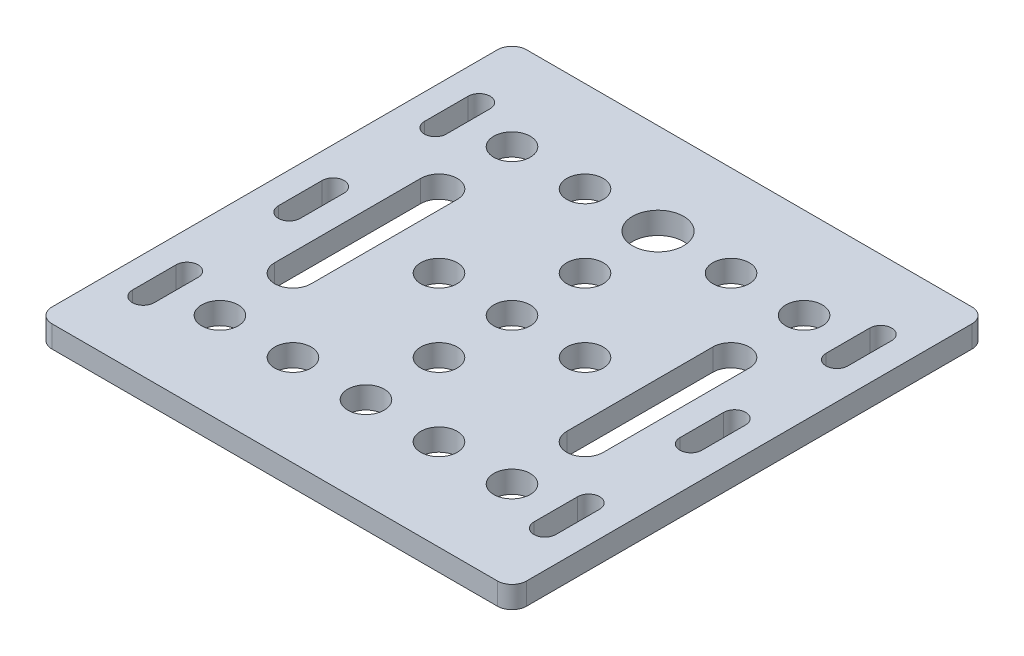
from build123d import *

# Parameters (mm, degrees)
SKETCH1_W               = 65
SKETCH1_H               = 65
BOSS_EXTRUDE1_DEPTH     = 1.5
CUT_EXTRUDE1_DEPTH      = 46.986411036
CUT_EXTRUDE1_DEPTH_BACK = 46.986411036
SKETCH2_R               = 2.5
CUT_EXTRUDE2_DEPTH      = 46.986411036
CUT_EXTRUDE2_DEPTH_BACK = 46.986411036
CUT_EXTRUDE3_DEPTH      = 46.986411036
CUT_EXTRUDE3_DEPTH_BACK = 46.986411036
SKETCH4_R               = 3.5
CUT_EXTRUDE4_DEPTH      = 46.986411036
CUT_EXTRUDE4_DEPTH_BACK = 46.986411036
FILLET1_R               = 2


with BuildPart() as part:
    # Sketch1 → Boss-Extrude1 (new, symmetric)
    with BuildSketch(Plane(origin=(0, 0, 0), x_dir=(1, 0, 0), z_dir=(0, 1, 0))):
        Rectangle(SKETCH1_W, SKETCH1_H)
    extrude(amount=BOSS_EXTRUDE1_DEPTH, both=True)

    # Sketch2 → Cut-Extrude1 (cut, two sides: drawn at the far end of the back side and taken through both)
    with BuildSketch(Plane(origin=(0, 0, 0), x_dir=(1, 0, 0), z_dir=(0, 1, 0)).offset(-CUT_EXTRUDE1_DEPTH_BACK)):
        Circle(SKETCH2_R)
        with Locations((0, 10)):
            Circle(SKETCH2_R)
        with Locations((0, -10)):
            Circle(SKETCH2_R)
        with Locations((0, -20)):
            Circle(SKETCH2_R)
        with Locations((-10, 0)):
            Circle(SKETCH2_R)
        with Locations((-10, 20)):
            Circle(SKETCH2_R)
        with Locations((-10, -20)):
            Circle(SKETCH2_R)
        with Locations((-20, 20)):
            Circle(SKETCH2_R)
        with Locations((-20, -20)):
            Circle(SKETCH2_R)
        with Locations((10, 0)):
            Circle(SKETCH2_R)
        with Locations((10, 20)):
            Circle(SKETCH2_R)
        with Locations((10, -20)):
            Circle(SKETCH2_R)
        with Locations((20, 20)):
            Circle(SKETCH2_R)
        with Locations((20, -20)):
            Circle(SKETCH2_R)
    extrude(amount=CUT_EXTRUDE1_DEPTH + CUT_EXTRUDE1_DEPTH_BACK, mode=Mode.SUBTRACT)

    # Sketch3 → Cut-Extrude2 (cut, two sides: drawn at the far end of the back side and taken through both)
    with BuildSketch(Plane(origin=(0, 0, 0), x_dir=(1, 0, 0), z_dir=(0, 1, 0)).offset(-CUT_EXTRUDE2_DEPTH_BACK)):
        with BuildLine():
            Line((22.5, 10), (22.5, -10))
            ThreePointArc((22.5, -10), (20, -12.5), (17.5, -10))
            Line((17.5, -10), (17.5, 10))
            ThreePointArc((17.5, 10), (20, 12.5), (22.5, 10))
        make_face()
        with BuildLine():
            Line((-22.5, 10), (-22.5, -10))
            ThreePointArc((-22.5, -10), (-20, -12.5), (-17.5, -10))
            Line((-17.5, -10), (-17.5, 10))
            ThreePointArc((-17.5, 10), (-20, 12.5), (-22.5, 10))
        make_face()
    extrude(amount=CUT_EXTRUDE2_DEPTH + CUT_EXTRUDE2_DEPTH_BACK, mode=Mode.SUBTRACT)

    # Sketch4 → Cut-Extrude3 (cut, two sides: drawn at the far end of the back side and taken through both)
    with BuildSketch(Plane(origin=(0, 0, 0), x_dir=(1, 0, 0), z_dir=(0, 1, 0)).offset(-CUT_EXTRUDE3_DEPTH_BACK)):
        with Locations((0, 20)):
            Circle(SKETCH4_R)
    extrude(amount=CUT_EXTRUDE3_DEPTH + CUT_EXTRUDE3_DEPTH_BACK, mode=Mode.SUBTRACT)

    # Sketch5 → Cut-Extrude4 (cut, two sides: drawn at the far end of the back side and taken through both)
    with BuildSketch(Plane(origin=(0, 0, 0), x_dir=(1, 0, 0), z_dir=(0, 1, 0)).offset(-CUT_EXTRUDE4_DEPTH_BACK)):
        with BuildLine():
            Line((29, -3), (29, 3))
            ThreePointArc((29, 3), (27.5, 4.5), (26, 3))
            Line((26, 3), (26, -3))
            ThreePointArc((26, -3), (27.5, -4.5), (29, -3))
        make_face()
        with BuildLine():
            Line((29, 17), (29, 23))
            ThreePointArc((29, 23), (27.5, 24.5), (26, 23))
            Line((26, 23), (26, 17))
            ThreePointArc((26, 17), (27.5, 15.5), (29, 17))
        make_face()
        with BuildLine():
            Line((29, -23), (29, -17))
            ThreePointArc((29, -17), (27.5, -15.5), (26, -17))
            Line((26, -17), (26, -23))
            ThreePointArc((26, -23), (27.5, -24.5), (29, -23))
        make_face()
        with BuildLine():
            ThreePointArc((-26, -17), (-27.5, -15.5), (-29, -17))
            Line((-29, -17), (-29, -23))
            ThreePointArc((-29, -23), (-27.5, -24.5), (-26, -23))
            Line((-26, -23), (-26, -17))
        make_face()
        with BuildLine():
            ThreePointArc((-26, 23), (-27.5, 24.5), (-29, 23))
            Line((-29, 23), (-29, 17))
            ThreePointArc((-29, 17), (-27.5, 15.5), (-26, 17))
            Line((-26, 17), (-26, 23))
        make_face()
        with BuildLine():
            ThreePointArc((-26, 3), (-27.5, 4.5), (-29, 3))
            Line((-29, 3), (-29, -3))
            ThreePointArc((-29, -3), (-27.5, -4.5), (-26, -3))
            Line((-26, -3), (-26, 3))
        make_face()
    extrude(amount=CUT_EXTRUDE4_DEPTH + CUT_EXTRUDE4_DEPTH_BACK, mode=Mode.SUBTRACT)

    # Fillet1
    fillet1_edges = [part.edges().sort_by_distance(p)[0] for p in [
        (-32.5, 0, 32.5),
        (32.5, 0, 32.5),
        (32.5, 0, -32.5),
        (-32.5, 0, -32.5),
    ]]
    fillet(fillet1_edges, radius=FILLET1_R)


solid = part.part
